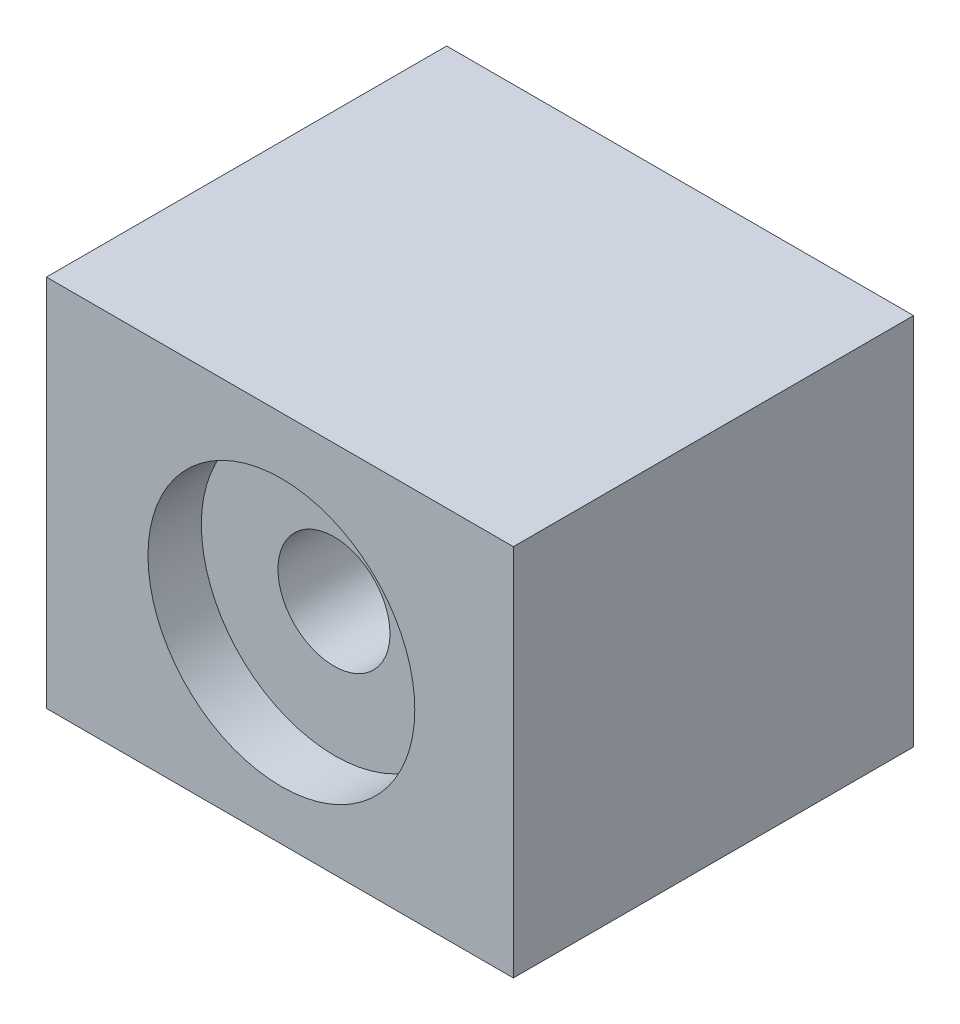
from build123d import *

# Parameters (mm, degrees)
SKETCH1_W           = 35
SKETCH1_H           = 30
BOSS_EXTRUDE1_DEPTH = 28
SKETCH2_R           = 10
SKETCH2_R_2         = 4
CUT_EXTRUDE1_DEPTH  = 4
SKETCH4_R           = 4.2
CUT_EXTRUDE2_DEPTH  = 48


with BuildPart() as part:
    # Sketch1 → Boss-Extrude1 (new body)
    with BuildSketch(Plane(origin=(0, 0, 0), x_dir=(1, 0, 0), z_dir=(0, 1, 0))):
        with Locations((-2.651515152, -4.217171717)):
            Rectangle(SKETCH1_W, SKETCH1_H)
    extrude(amount=BOSS_EXTRUDE1_DEPTH)

    # Sketch2 → Cut-Extrude1 (cut)
    with BuildSketch(Plane.XY.offset(19.217171717)):
        with Locations((-2.538807386, 13.733372101)):
            Circle(SKETCH2_R)
        with Locations((-2.538807386, 13.733372101)):
            Circle(SKETCH2_R_2, mode=Mode.SUBTRACT)
    extrude(amount=-CUT_EXTRUDE1_DEPTH, mode=Mode.SUBTRACT)

    # Sketch4 → Cut-Extrude2 (cut)
    with BuildSketch(Plane.XY.offset(19.217171717)):
        with Locations((-2.597602696, 13.723084653)):
            Circle(SKETCH4_R)
    extrude(amount=-CUT_EXTRUDE2_DEPTH, mode=Mode.SUBTRACT)


solid = part.part
